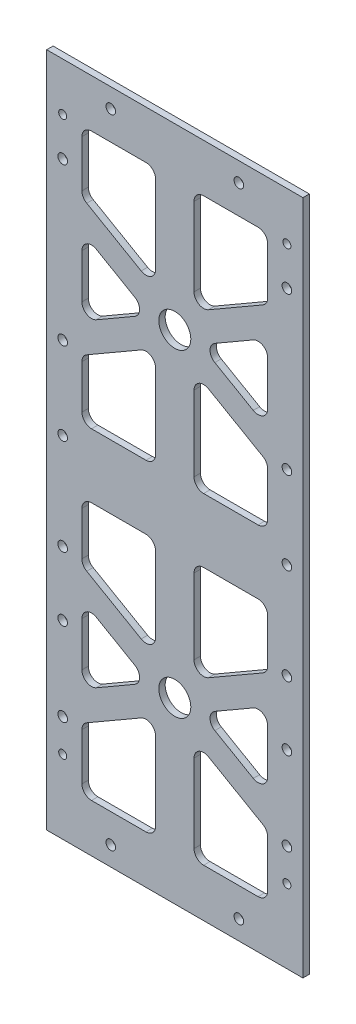
from build123d import *

# Parameters (mm, degrees)
SKETCH1_W                   = 88
SKETCH1_H                   = 211
BOSS_EXTRUDE1_DEPTH         = 2
CUT_EXTRUDE2_DEPTH          = 2
SKETCH4_R                   = 5
CUT_EXTRUDE3_DEPTH          = 3
FILLET2_R                   = 3
SKETCH23_W                  = 2
SKETCH23_H                  = 211
SKETCH23_W_2                = 2.150374681
CUT_EXTRUDE5_DEPTH          = 10
SKETCH29_W                  = 5.911493913
SKETCH29_H                  = 211
SKETCH29_W_2                = 4.036537762
CUT_EXTRUDE10_DEPTH         = 2
F_3_0MM_DOWEL_HOLE1_D       = 3
TAP_DRILL_FOR_M3X0_5_TAP1_D = 2.5


with BuildPart() as part:
    # Sketch1 → Boss-Extrude1 (new body)
    with BuildSketch(Plane.XY):
        with Locations((44, 105.5)):
            Rectangle(SKETCH1_W, SKETCH1_H)
    extrude(amount=BOSS_EXTRUDE1_DEPTH)

    # Sketch3 → Cut-Extrude2 (cut)
    with BuildSketch(Plane.XY.offset(2)):
        Polygon((73, 133.88804004), (50, 147.167096231), (50, 115.5), (73, 115.5), align=None)
        Polygon((38, 115.5), (38, 147.167096231), (15, 133.88804004), (15, 115.5), align=None)
        Polygon((15, 143.125644347), (36, 155.25), (15, 167.374355653), align=None)
        Polygon((73, 143.125644347), (73, 167.374355653), (52, 155.25), align=None)
        Polygon((73, 196), (50, 196), (50, 163.332903769), (73, 176.61195996), align=None)
        Polygon((38, 163.332903769), (38, 196), (15, 196), (15, 176.61195996), align=None)
    cut_extrude2 = extrude(amount=-CUT_EXTRUDE2_DEPTH, mode=Mode.SUBTRACT)

    # Sketch4 → Cut-Extrude3 (cut, through all)
    with BuildSketch(Plane.XY.offset(2)):
        with Locations((44, 155.25)):
            Circle(SKETCH4_R)
    cut_extrude3 = extrude(amount=-CUT_EXTRUDE3_DEPTH, mode=Mode.SUBTRACT)

    # Mirror2: Cut-Extrude2, Cut-Extrude3 across plane
    add(cut_extrude2.mirror(Plane.ZX.offset(105.5)), mode=Mode.SUBTRACT)
    add(cut_extrude3.mirror(Plane.ZX.offset(105.5)), mode=Mode.SUBTRACT)

    # Fillet2
    fillet2_edges = [part.edges().sort_by_distance(p)[0] for p in [
        (36, 55.75, 1),
        (15, 43.625644347, 1),
        (15, 67.874355653, 1),
        (38, 95.5, 1),
        (38, 63.832903769, 1),
        (15, 77.11195996, 1),
        (15, 95.5, 1),
        (73, 15, 1),
        (50, 15, 1),
        (50, 47.667096231, 1),
        (73, 34.38804004, 1),
        (73, 43.625644347, 1),
        (52, 55.75, 1),
        (73, 67.874355653, 1),
        (15, 15, 1),
        (15, 34.38804004, 1),
        (38, 47.667096231, 1),
        (38, 15, 1),
        (73, 77.11195996, 1),
        (50, 63.832903769, 1),
        (50, 95.5, 1),
        (73, 95.5, 1),
        (15, 167.374355653, 1),
        (36, 155.25, 1),
        (15, 143.125644347, 1),
        (38, 147.167096231, 1),
        (38, 115.5, 1),
        (15, 115.5, 1),
        (15, 133.88804004, 1),
        (50, 196, 1),
        (73, 196, 1),
        (73, 176.61195996, 1),
        (50, 163.332903769, 1),
        (52, 155.25, 1),
        (73, 167.374355653, 1),
        (73, 143.125644347, 1),
        (15, 176.61195996, 1),
        (15, 196, 1),
        (38, 196, 1),
        (38, 163.332903769, 1),
        (50, 147.167096231, 1),
        (73, 133.88804004, 1),
        (73, 115.5, 1),
        (50, 115.5, 1),
    ]]
    fillet(fillet2_edges, radius=FILLET2_R)

    # Sketch23 → Cut-Extrude5 (cut)
    with BuildSketch(Plane.XY.offset(2)):
        with Locations((87, 105.5)):
            Rectangle(SKETCH23_W, SKETCH23_H)
        with Locations((1.075187341, 105.5)):
            Rectangle(SKETCH23_W_2, SKETCH23_H)
    extrude(amount=-CUT_EXTRUDE5_DEPTH, mode=Mode.SUBTRACT)

    # Sketch29 → Cut-Extrude10 (cut)
    with BuildSketch(Plane(origin=(0, 0, 0), x_dir=(-1, 0, 0), z_dir=(0, 0, -1))):
        with Locations((-1.044253043, 105.5)):
            Rectangle(SKETCH29_W, SKETCH29_H)
        with Locations((-86.018268881, 105.5)):
            Rectangle(SKETCH29_W_2, SKETCH29_H)
    extrude(amount=-CUT_EXTRUDE10_DEPTH, mode=Mode.SUBTRACT)

    # Ø3.0mm Dowel Hole1 (through all)
    with Locations(Plane.XY.offset(2)):
        with Locations((24, 205), (64, 205), (9, 184), (79, 184), (9, 135), (79, 135), (79, 109.2), (9, 109.2), (9, 79.2), (79, 79.2), (79, 59.2), (9, 59.2), (9, 33.2), (79, 33.2), (64, 6), (24, 6)):
            Hole(F_3_0MM_DOWEL_HOLE1_D / 2)

    # Tap Drill for M3x0.5 Tap1 (through all)
    with Locations(Plane.XY.offset(2)):
        with Locations((9, 23), (79, 23), (9, 196), (79, 196)):
            Hole(TAP_DRILL_FOR_M3X0_5_TAP1_D / 2)


solid = part.part
